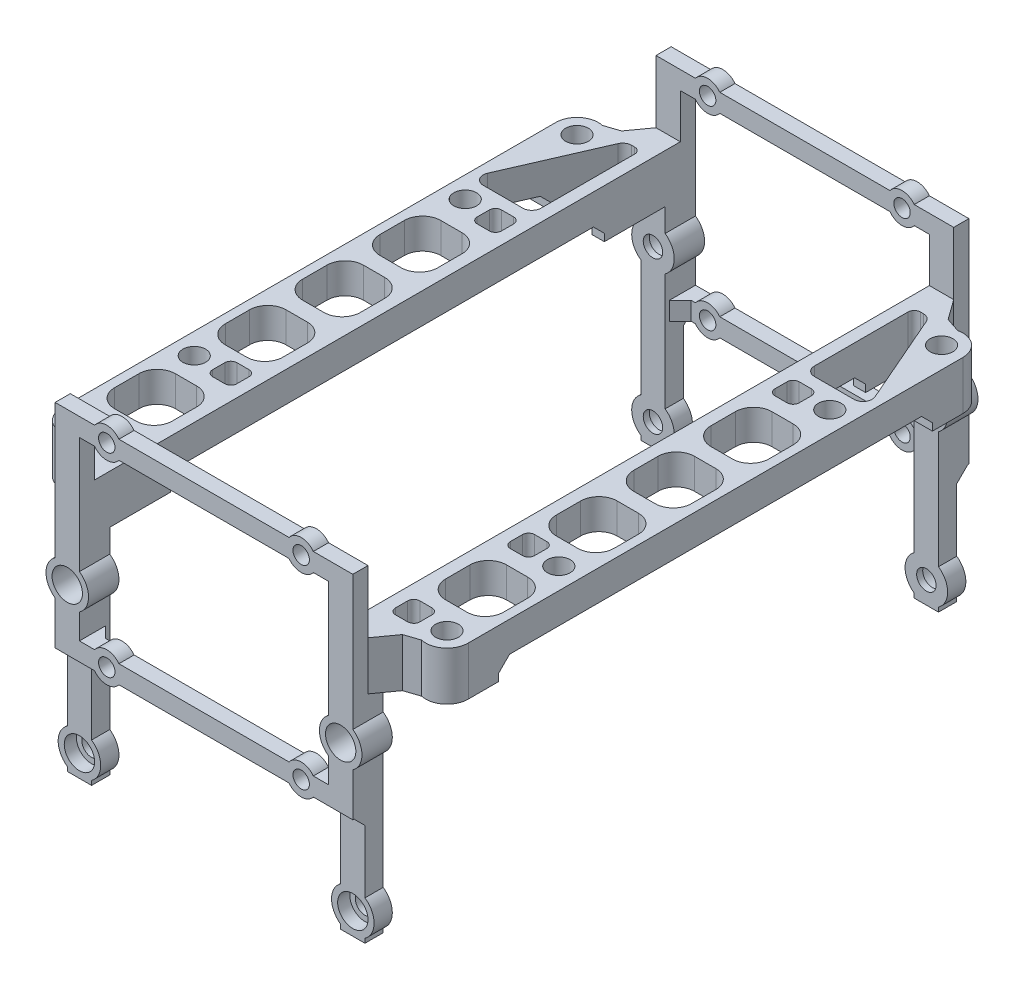
from build123d import *

# Parameters (mm, degrees)
BOSS_EXTRUDE1_DEPTH      = 4
SKETCH2_R                = 1.6
CUT_EXTRUDE1_DEPTH       = 49.7
CUT_EXTRUDE1_DEPTH_BACK  = 1
SKETCH3_R                = 1.35
SKETCH3_R_2              = 2.5
BOSS_EXTRUDE2_DEPTH      = 2
BOSS_EXTRUDE2_DEPTH_BACK = 0.5
BOSS_EXTRUDE3_DEPTH      = 8
SKETCH10_R               = 3.5
SKETCH10_R_2             = 1.6
BOSS_EXTRUDE5_DEPTH      = 3
SKETCH11_R               = 2.5
CUT_EXTRUDE4_DEPTH       = 2
SKETCH8_R                = 1.875
CUT_EXTRUDE3_DEPTH       = 44.3
CHAMFER1_SIZE            = 2.5
SKETCH12_R               = 3
CUT_EXTRUDE7_DEPTH       = 4.5
SKETCH13_W               = 71.4
SKETCH13_H               = 7.385436
CUT_EXTRUDE8_DEPTH       = 68
CHAMFER2_SIZE            = 1.8
CHAMFER3_SIZE            = 1.8
CHAMFER4_SIZE            = 1.8


with BuildPart() as part:
    # Sketch1 → Boss-Extrude1 (new body)
    with BuildSketch(Plane(origin=(0, 0, 0), x_dir=(0, 0, -1), z_dir=(1, 0, 0))):
        Polygon((91.4, 35.3), (45.7, 35.3), (45.7, 43.3), (94.4, 43.3), (94.4, 0), (91.4, 0), align=None)
    extrude(amount=BOSS_EXTRUDE1_DEPTH)

    # Sketch2 → Cut-Extrude1 (cut, two sides)
    with BuildSketch(Plane.XY.offset(-94.4)) as cut_extrude1_sk:
        with Locations((2, 28.6)):
            Circle(SKETCH2_R)
        with Locations((2, 3.6)):
            Circle(SKETCH2_R)
    extrude(amount=CUT_EXTRUDE1_DEPTH, mode=Mode.SUBTRACT)
    extrude(cut_extrude1_sk.sketch, amount=-CUT_EXTRUDE1_DEPTH_BACK, mode=Mode.SUBTRACT)

    # Sketch3 → Boss-Extrude2 (add, two sides)
    with BuildSketch(Plane(origin=(0, 0, -94.4), x_dir=(-1, 0, 0), z_dir=(0, 0, -1))) as boss_extrude2_sk:
        with BuildLine():
            Line((20.5, 53.6), (6.5, 53.6))
            ThreePointArc((6.5, 53.6), (4.5, 54.6), (2.5, 53.6))
            Line((2.5, 53.6), (-4, 53.6))
            Line((-4, 53.6), (-4, 31.472281))
            ThreePointArc((-4, 31.472281), (-5.5, 28.6), (-4, 25.727719))
            Line((-4, 25.727719), (-4, 18.6))
            Line((-4, 18.6), (2.5, 18.6))
            ThreePointArc((2.5, 18.6), (4.5, 17.6), (6.5, 18.6))
            Line((6.5, 18.6), (20.5, 18.6))
            Line((20.5, 18.6), (20.5, 21.6))
            Line((20.5, 21.6), (6.5, 21.6))
            ThreePointArc((6.5, 21.6), (4.5, 22.6), (2.5, 21.6))
            Line((2.5, 21.6), (0, 21.6))
            Line((0, 21.6), (0, 25.727719))
            ThreePointArc((0, 25.727719), (1.5, 28.6), (0, 31.472281))
            Line((0, 31.472281), (0, 50.6))
            Line((0, 50.6), (2.5, 50.6))
            ThreePointArc((2.5, 50.6), (4.5, 49.6), (6.5, 50.6))
            Line((6.5, 50.6), (20.5, 50.6))
            Line((20.5, 50.6), (20.5, 53.6))
        make_face()
        with Locations((4.5, 52.1)):
            Circle(SKETCH3_R, mode=Mode.SUBTRACT)
        with Locations((-2, 28.6)):
            Circle(SKETCH3_R_2, mode=Mode.SUBTRACT)
        with Locations((4.5, 20.1)):
            Circle(SKETCH3_R, mode=Mode.SUBTRACT)
    extrude(amount=BOSS_EXTRUDE2_DEPTH)
    extrude(boss_extrude2_sk.sketch, amount=-BOSS_EXTRUDE2_DEPTH_BACK)

    # Sketch5 → Boss-Extrude3 (add)
    with BuildSketch(Plane(origin=(0, 43.3, 0), x_dir=(1, 0, 0), z_dir=(0, 1, 0))):
        with BuildLine():
            Line((4, 91.4), (8.746327, 89.817891))
            ThreePointArc((8.746327, 89.817891), (11.692276, 89.128356), (13, 86.4))
            Line((13, 86.4), (13, 45.7))
            Line((13, 45.7), (0, 45.7))
            Line((0, 45.7), (0, 91.4))
            Line((0, 91.4), (4, 91.4))
        make_face()
    extrude(amount=-BOSS_EXTRUDE3_DEPTH)

    # Sketch10 → Boss-Extrude5 (add)
    with BuildSketch(Plane(origin=(0, 0, -94.4), x_dir=(-1, 0, 0), z_dir=(0, 0, -1))):
        with Locations((-2, 28.6)):
            Circle(SKETCH10_R)
        with Locations((-2, 28.6)):
            Circle(SKETCH10_R_2, mode=Mode.SUBTRACT)
        with Locations((-2, 3.6)):
            Circle(SKETCH10_R)
        with Locations((-2, 3.6)):
            Circle(SKETCH10_R_2, mode=Mode.SUBTRACT)
    extrude(amount=-BOSS_EXTRUDE5_DEPTH)

    # Sketch11 → Cut-Extrude4 (cut)
    with BuildSketch(Plane(origin=(0, 0, -94.4), x_dir=(-1, 0, 0), z_dir=(0, 0, -1))):
        with Locations((-2, 28.6)):
            Circle(SKETCH11_R)
        with Locations((-2, 3.6)):
            Circle(SKETCH11_R)
    extrude(amount=-CUT_EXTRUDE4_DEPTH, mode=Mode.SUBTRACT)

    # Mirror4: part across plane


with BuildPart() as part_1:
    add(part.part)
    add(part.part.mirror(Plane(origin=(-20.5, 0, -96.4), x_dir=(0, 0, 1), z_dir=(-1, 0, 0))))

    # Mirror5: part across plane


with BuildPart() as part_2:
    add(part_1.part)
    add(part_1.part.mirror(Plane(origin=(4, 0, -45.7), x_dir=(1, 0, 0), z_dir=(0, 0, -1))))

    # Sketch8 → Cut-Extrude3 (cut, through all)
    with BuildSketch(Plane(origin=(0, 43.3, 0), x_dir=(1, 0, 0), z_dir=(0, 1, 0))):
        with Locations((9.5, 86.4)):
            Circle(SKETCH8_R)
        with Locations((9.5, 5)):
            Circle(SKETCH8_R)
        with Locations((9.5, 23.4)):
            Circle(SKETCH8_R)
        with Locations((9.5, 68)):
            Circle(SKETCH8_R)
        with Locations((-50.5, 68)):
            Circle(SKETCH8_R)
        with Locations((-50.5, 23.4)):
            Circle(SKETCH8_R)
        with Locations((-50.5, 5)):
            Circle(SKETCH8_R)
        with Locations((-50.5, 86.4)):
            Circle(SKETCH8_R)
        with BuildLine():
            Line((5, 50.241464), (8.5, 50.241464))
            ThreePointArc((8.5, 50.241464), (10.62132, 49.362784), (11.5, 47.241464))
            Line((11.5, 47.241464), (11.5, 43.241464))
            ThreePointArc((11.5, 43.241464), (10.62132, 41.120144), (8.5, 40.241464))
            Line((8.5, 40.241464), (5, 40.241464))
            ThreePointArc((5, 40.241464), (2.87868, 41.120144), (2, 43.241464))
            Line((2, 43.241464), (2, 47.241464))
            ThreePointArc((2, 47.241464), (2.87868, 49.362784), (5, 50.241464))
        make_face()
        with BuildLine():
            Line((5, 62.974937), (8.5, 62.974937))
            ThreePointArc((8.5, 62.974937), (10.62132, 62.096258), (11.5, 59.974937))
            Line((11.5, 59.974937), (11.5, 55.974937))
            ThreePointArc((11.5, 55.974937), (10.62132, 53.853617), (8.5, 52.974937))
            Line((8.5, 52.974937), (5, 52.974937))
            ThreePointArc((5, 52.974937), (2.87868, 53.853617), (2, 55.974937))
            Line((2, 55.974937), (2, 59.974937))
            ThreePointArc((2, 59.974937), (2.87868, 62.096258), (5, 62.974937))
        make_face()
        with BuildLine():
            Line((2, 88.4), (2, 72.974937))
            ThreePointArc((2, 72.974937), (2.43934, 71.914277), (3.5, 71.474937))
            Line((3.5, 71.474937), (10, 71.474937))
            ThreePointArc((10, 71.474937), (11.25467, 72.152865), (11.37524, 73.573866))
            Line((11.37524, 73.573866), (4.87524, 88.498929))
            ThreePointArc((4.87524, 88.498929), (4.322072, 89.15467), (3.5, 89.4))
            Line((3.5, 89.4), (3, 89.4))
            ThreePointArc((3, 89.4), (2.292893, 89.107107), (2, 88.4))
        make_face()
        with BuildLine():
            Line((3, 69.474937), (5, 69.474937))
            ThreePointArc((5, 69.474937), (5.707107, 69.182044), (6, 68.474937))
            Line((6, 68.474937), (6, 66.474937))
            ThreePointArc((6, 66.474937), (5.707107, 65.76783), (5, 65.474937))
            Line((5, 65.474937), (3, 65.474937))
            ThreePointArc((3, 65.474937), (2.292893, 65.76783), (2, 66.474937))
            Line((2, 66.474937), (2, 68.474937))
            ThreePointArc((2, 68.474937), (2.292893, 69.182044), (3, 69.474937))
        make_face()
        with BuildLine():
            Line((5, 37.507991), (8.5, 37.507991))
            ThreePointArc((8.5, 37.507991), (10.62132, 36.629311), (11.5, 34.507991))
            Line((11.5, 34.507991), (11.5, 30.507991))
            ThreePointArc((11.5, 30.507991), (10.62132, 28.38667), (8.5, 27.507991))
            Line((8.5, 27.507991), (5, 27.507991))
            ThreePointArc((5, 27.507991), (2.87868, 28.38667), (2, 30.507991))
            Line((2, 30.507991), (2, 34.507991))
            ThreePointArc((2, 34.507991), (2.87868, 36.629311), (5, 37.507991))
        make_face()
        with BuildLine():
            Line((6, 22.925063), (6, 24.925063))
            ThreePointArc((6, 24.925063), (5.707107, 25.63217), (5, 25.925063))
            Line((5, 25.925063), (3, 25.925063))
            ThreePointArc((3, 25.925063), (2.292893, 25.63217), (2, 24.925063))
            Line((2, 24.925063), (2, 22.925063))
            ThreePointArc((2, 22.925063), (2.292893, 22.217956), (3, 21.925063))
            Line((3, 21.925063), (5, 21.925063))
            ThreePointArc((5, 21.925063), (5.707107, 22.217956), (6, 22.925063))
        make_face()
        with BuildLine():
            Line((11.5, 12.292009), (11.5, 16.292009))
            ThreePointArc((11.5, 16.292009), (10.62132, 18.41333), (8.5, 19.292009))
            Line((8.5, 19.292009), (5, 19.292009))
            ThreePointArc((5, 19.292009), (2.87868, 18.41333), (2, 16.292009))
            Line((2, 16.292009), (2, 12.292009))
            ThreePointArc((2, 12.292009), (2.87868, 10.170689), (5, 9.292009))
            Line((5, 9.292009), (8.5, 9.292009))
            ThreePointArc((8.5, 9.292009), (10.62132, 10.170689), (11.5, 12.292009))
        make_face()
        with BuildLine():
            Line((-46, 9.292009), (-49.5, 9.292009))
            ThreePointArc((-49.5, 9.292009), (-51.62132, 10.170689), (-52.5, 12.292009))
            Line((-52.5, 12.292009), (-52.5, 16.292009))
            ThreePointArc((-52.5, 16.292009), (-51.62132, 18.41333), (-49.5, 19.292009))
            Line((-49.5, 19.292009), (-46, 19.292009))
            ThreePointArc((-46, 19.292009), (-43.87868, 18.41333), (-43, 16.292009))
            Line((-43, 16.292009), (-43, 12.292009))
            ThreePointArc((-43, 12.292009), (-43.87868, 10.170689), (-46, 9.292009))
        make_face()
        with BuildLine():
            Line((-44, 21.925063), (-46, 21.925063))
            ThreePointArc((-46, 21.925063), (-46.707107, 22.217956), (-47, 22.925063))
            Line((-47, 22.925063), (-47, 24.925063))
            ThreePointArc((-47, 24.925063), (-46.707107, 25.63217), (-46, 25.925063))
            Line((-46, 25.925063), (-44, 25.925063))
            ThreePointArc((-44, 25.925063), (-43.292893, 25.63217), (-43, 24.925063))
            Line((-43, 24.925063), (-43, 22.925063))
            ThreePointArc((-43, 22.925063), (-43.292893, 22.217956), (-44, 21.925063))
        make_face()
        with BuildLine():
            Line((-52.5, 34.507991), (-52.5, 30.507991))
            ThreePointArc((-52.5, 30.507991), (-51.62132, 28.38667), (-49.5, 27.507991))
            Line((-49.5, 27.507991), (-46, 27.507991))
            ThreePointArc((-46, 27.507991), (-43.87868, 28.38667), (-43, 30.507991))
            Line((-43, 30.507991), (-43, 34.507991))
            ThreePointArc((-43, 34.507991), (-43.87868, 36.629311), (-46, 37.507991))
            Line((-46, 37.507991), (-49.5, 37.507991))
            ThreePointArc((-49.5, 37.507991), (-51.62132, 36.629311), (-52.5, 34.507991))
        make_face()
        with BuildLine():
            Line((-52.5, 47.241464), (-52.5, 43.241464))
            ThreePointArc((-52.5, 43.241464), (-51.62132, 41.120144), (-49.5, 40.241464))
            Line((-49.5, 40.241464), (-46, 40.241464))
            ThreePointArc((-46, 40.241464), (-43.87868, 41.120144), (-43, 43.241464))
            Line((-43, 43.241464), (-43, 47.241464))
            ThreePointArc((-43, 47.241464), (-43.87868, 49.362784), (-46, 50.241464))
            Line((-46, 50.241464), (-49.5, 50.241464))
            ThreePointArc((-49.5, 50.241464), (-51.62132, 49.362784), (-52.5, 47.241464))
        make_face()
        with BuildLine():
            Line((-47, 68.474937), (-47, 66.474937))
            ThreePointArc((-47, 66.474937), (-46.707107, 65.76783), (-46, 65.474937))
            Line((-46, 65.474937), (-44, 65.474937))
            ThreePointArc((-44, 65.474937), (-43.292893, 65.76783), (-43, 66.474937))
            Line((-43, 66.474937), (-43, 68.474937))
            ThreePointArc((-43, 68.474937), (-43.292893, 69.182044), (-44, 69.474937))
            Line((-44, 69.474937), (-46, 69.474937))
            ThreePointArc((-46, 69.474937), (-46.707107, 69.182044), (-47, 68.474937))
        make_face()
        with BuildLine():
            Line((-52.5, 59.974937), (-52.5, 55.974937))
            ThreePointArc((-52.5, 55.974937), (-51.62132, 53.853617), (-49.5, 52.974937))
            Line((-49.5, 52.974937), (-46, 52.974937))
            ThreePointArc((-46, 52.974937), (-43.87868, 53.853617), (-43, 55.974937))
            Line((-43, 55.974937), (-43, 59.974937))
            ThreePointArc((-43, 59.974937), (-43.87868, 62.096258), (-46, 62.974937))
            Line((-46, 62.974937), (-49.5, 62.974937))
            ThreePointArc((-49.5, 62.974937), (-51.62132, 62.096258), (-52.5, 59.974937))
        make_face()
        with BuildLine():
            Line((-44.5, 89.4), (-44, 89.4))
            ThreePointArc((-44, 89.4), (-43.292893, 89.107107), (-43, 88.4))
            Line((-43, 88.4), (-43, 72.974937))
            ThreePointArc((-43, 72.974937), (-43.43934, 71.914277), (-44.5, 71.474937))
            Line((-44.5, 71.474937), (-51, 71.474937))
            ThreePointArc((-51, 71.474937), (-52.25467, 72.152865), (-52.37524, 73.573866))
            Line((-52.37524, 73.573866), (-45.87524, 88.498929))
            ThreePointArc((-45.87524, 88.498929), (-45.322072, 89.15467), (-44.5, 89.4))
        make_face()
        with BuildLine():
            Line((6, 3.969435), (6, 6.030565))
            ThreePointArc((6, 6.030565), (5.707107, 6.737672), (5, 7.030565))
            Line((5, 7.030565), (3, 7.030565))
            ThreePointArc((3, 7.030565), (2.292893, 6.737672), (2, 6.030565))
            Line((2, 6.030565), (2, 4.030565))
            ThreePointArc((2, 4.030565), (2.292893, 3.323458), (3, 3.030565))
            Line((3, 3.030565), (5, 3.030565))
            ThreePointArc((5, 3.030565), (5.686342, 3.301525), (6, 3.969435))
        make_face()
        with BuildLine():
            Line((-44, 3.030565), (-46, 3.030565))
            ThreePointArc((-46, 3.030565), (-46.686342, 3.301525), (-47, 3.969435))
            Line((-47, 3.969435), (-47, 6.030565))
            ThreePointArc((-47, 6.030565), (-46.707107, 6.737672), (-46, 7.030565))
            Line((-46, 7.030565), (-44, 7.030565))
            ThreePointArc((-44, 7.030565), (-43.292893, 6.737672), (-43, 6.030565))
            Line((-43, 6.030565), (-43, 4.030565))
            ThreePointArc((-43, 4.030565), (-43.292893, 3.323458), (-44, 3.030565))
        make_face()
    extrude(amount=-CUT_EXTRUDE3_DEPTH, mode=Mode.SUBTRACT)

    # Chamfer1
    chamfer1_edges = [part_2.edges().sort_by_distance(p)[0] for p in [
        (-45, 39.3, 0),
        (-45, 39.3, -91.4),
        (4, 39.3, 0),
        (4, 39.3, -91.4),
    ]]
    chamfer(chamfer1_edges, length=CHAMFER1_SIZE)

    # Sketch12 → Cut-Extrude7 (cut)
    with BuildSketch(Plane.XZ.offset(-35.3)):
        with Locations((9.5, -5)):
            Circle(SKETCH12_R)
        with Locations((9.5, -23.4)):
            Circle(SKETCH12_R)
        with Locations((9.5, -86.4)):
            Circle(SKETCH12_R)
        with Locations((9.5, -68)):
            Circle(SKETCH12_R)
        with Locations((-50.5, -86.4)):
            Circle(SKETCH12_R)
        with Locations((-50.5, -68)):
            Circle(SKETCH12_R)
        with Locations((-50.5, -23.4)):
            Circle(SKETCH12_R)
        with Locations((-50.5, -5)):
            Circle(SKETCH12_R)
    extrude(amount=-CUT_EXTRUDE7_DEPTH, mode=Mode.SUBTRACT)

    # Sketch13 → Cut-Extrude8 (cut, through all)
    with BuildSketch(Plane.ZY.offset(54)):
        with Locations((-45.7, 34.607282)):
            Rectangle(SKETCH13_W, SKETCH13_H)
    extrude(amount=-CUT_EXTRUDE8_DEPTH, mode=Mode.SUBTRACT)

    # Chamfer2
    chamfer2_edges = [part_2.edges().sort_by_distance(p)[0] for p in [
        (-43, 18.6, -94.4),
        (2, 18.6, 3),
        (-43, 18.6, 3),
        (2, 18.6, -94.4),
    ]]
    chamfer(chamfer2_edges, length=CHAMFER2_SIZE)

    # Chamfer3
    chamfer3_edges = [part_2.edges().sort_by_distance(p)[0] for p in [
        (-41, 20.1, -93.9),
        (0, 20.1, -93.9),
        (0, 20.1, 2.5),
        (-41, 20.1, 2.5),
    ]]
    chamfer(chamfer3_edges, length=CHAMFER3_SIZE)

    # Chamfer4
    chamfer4_edges = [part_2.edges().sort_by_distance(p)[0] for p in [
        (-42.532181, 38.3, -10),
        (-52.717819, 38.3, -10),
        (1.532181, 38.3, -10),
        (1, 38.3, -81.4),
        (10.483444, 38.3, -81.4),
        (-42, 38.3, -81.4),
        (-51.483444, 38.3, -81.4),
        (11.717819, 38.3, -10),
    ]]
    chamfer(chamfer4_edges, length=CHAMFER4_SIZE)


solid = part_2.part
